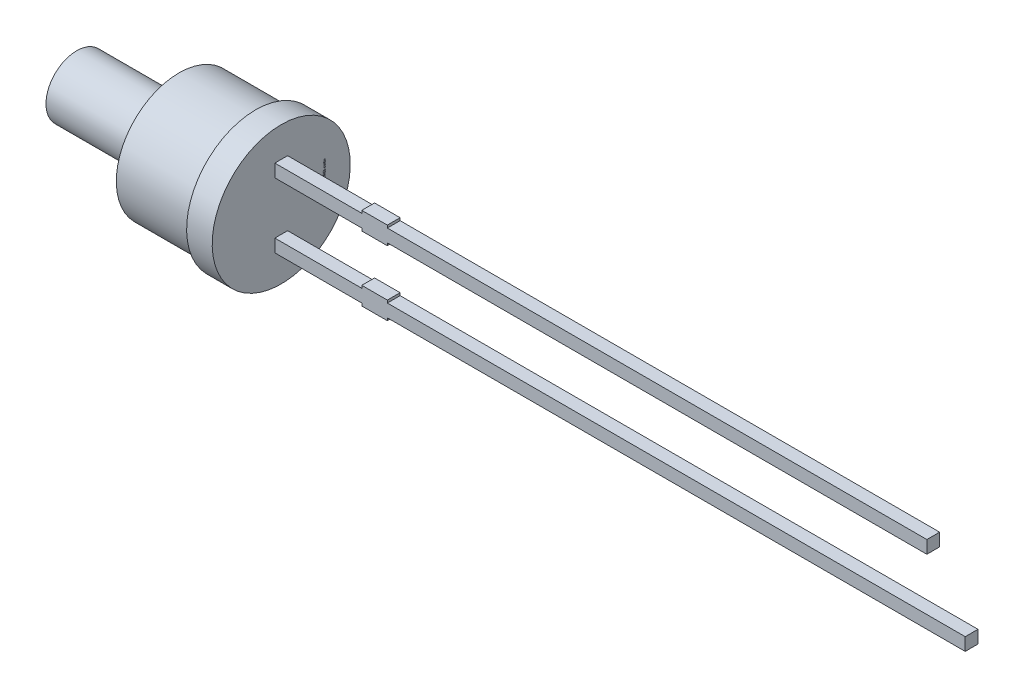
from build123d import *

# Parameters (mm, degrees)
SKETCH1_W          = 3.4
SKETCH1_H          = 0.5
SKETCH1_W_2        = 1
SKETCH1_W_3        = 21.1
SKETCH1_H_2        = 0.1
SKETCH1_W_4        = 22.6
EXTRUDE2_DEPTH     = 0.25
SKETCH2_W          = 0.026582279
SKETCH2_H          = 0.025316456
CUT_EXTRUDE1_DEPTH = 0.01


with BuildPart() as part:
    # Sketch1 → Extrude2 (new body, symmetric)
    with BuildSketch(Plane.XY):
        with Locations((1.7, 1.27)):
            Rectangle(SKETCH1_W, SKETCH1_H)
        with Locations((3.9, 1.27)):
            Rectangle(SKETCH1_W_2, SKETCH1_H)
        with Locations((14.95, 1.27)):
            Rectangle(SKETCH1_W_3, SKETCH1_H)
        with Locations((3.9, 1.57)):
            Rectangle(SKETCH1_W_2, SKETCH1_H_2)
        with Locations((3.9, 0.97)):
            Rectangle(SKETCH1_W_2, SKETCH1_H_2)
        with Locations((3.9, -1.27)):
            Rectangle(SKETCH1_W_2, SKETCH1_H)
        with Locations((3.9, -0.97)):
            Rectangle(SKETCH1_W_2, SKETCH1_H_2)
        with Locations((15.7, -1.27)):
            Rectangle(SKETCH1_W_4, SKETCH1_H)
        with Locations((1.7, -1.27)):
            Rectangle(SKETCH1_W, SKETCH1_H)
        with Locations((3.9, -1.57)):
            Rectangle(SKETCH1_W_2, SKETCH1_H_2)
    extrude(amount=EXTRUDE2_DEPTH, both=True)

    # Sketch1_6 → Revolve1 (revolve)
    with BuildSketch(Plane.XY):
        Polygon((-8, 0), (0, 0), (0, 1.02), (0, 1.52), (0, 2.7), (-1, 2.7), (-1, 2.45), (-4, 2.45), (-4, 1.2), (-8, 1.2), align=None)
    revolve(axis=Axis((0, 0, 0), (-1, 0, 0)))

    # Sketch2 → Cut-Extrude1 (cut)
    with BuildSketch(Plane(origin=(0, 0, 0), x_dir=(0, 0, -1), z_dir=(1, 0, 0))):
        Polygon((1.660977077, -0.572151899), (1.735660621, -0.595609177), (1.735660621, -0.620352057), (1.685324387, -0.636768196), (1.735660621, -0.652294304), (1.735660621, -0.678026108), (1.660977077, -0.701265823), (1.660977077, -0.676087816), (1.712460463, -0.663093354), (1.660977077, -0.646677215), (1.660977077, -0.625178006), (1.712460463, -0.608860759), (1.660977077, -0.596044304), align=None)
        Polygon((1.660977077, -0.437974684), (1.735660621, -0.461431962), (1.735660621, -0.486174842), (1.685324387, -0.502590981), (1.735660621, -0.518117089), (1.735660621, -0.543848892), (1.660977077, -0.567088608), (1.660977077, -0.541910601), (1.712460463, -0.528916139), (1.660977077, -0.5125), (1.660977077, -0.491000791), (1.712460463, -0.474683544), (1.660977077, -0.461867089), align=None)
        Polygon((1.660977077, -0.303797468), (1.735660621, -0.327254747), (1.735660621, -0.351997627), (1.685324387, -0.368413766), (1.735660621, -0.383939873), (1.735660621, -0.409671677), (1.660977077, -0.432911392), (1.660977077, -0.407733386), (1.712460463, -0.394738924), (1.660977077, -0.378322785), (1.660977077, -0.356823576), (1.712460463, -0.340506329), (1.660977077, -0.327689873), align=None)
        with Locations((1.722369482, -0.275949367)):
            Rectangle(SKETCH2_W, SKETCH2_H)
        with BuildLine():
            add(Edge.make_bspline(
                [(1.704489735, -0.159493671), (1.705711857, -0.15953019), (1.708111696, -0.159601901), (1.711619553, -0.160211194), (1.714943236, -0.161206237), (1.718104474, -0.162572352), (1.721068901, -0.164381718), (1.723864915, -0.166563022), (1.726479114, -0.169150529), (1.728887641, -0.17210691), (1.731092305, -0.175388005), (1.732983411, -0.178990487), (1.734609946, -0.182859482), (1.735941121, -0.187013878), (1.736932036, -0.191459348), (1.737655311, -0.196177156), (1.73812883, -0.201170496), (1.73817077, -0.204594085), (1.738192266, -0.206348892)],
                knots=[0, 0, 0, 0, 0.907462679, 1.781953809, 2.635804048, 3.480274448, 4.332887508, 5.208817748, 6.109340518, 7.059474472, 8.037577805, 9.041105121, 10.077237313, 11.152245627, 12.27748741, 13.457227022, 14.696666784, 16, 16, 16, 16], degree=3))
            add(Edge.make_bspline(
                [(1.738192266, -0.206348892), (1.738165001, -0.208366877), (1.738112198, -0.212275063), (1.737726825, -0.217942631), (1.737038875, -0.223206098), (1.736082295, -0.228103845), (1.73487901, -0.232708145), (1.733588366, -0.23714149), (1.732123785, -0.241422782), (1.731023649, -0.244195874), (1.730478659, -0.24556962)],
                knots=[0, 0, 0, 0, 1.203182053, 2.33017619, 3.384818652, 4.366208123, 5.30340534, 6.221361684, 7.118890722, 8, 8, 8, 8], degree=3))
            Line((1.730478659, -0.24556962), (1.706546697, -0.24556962))
            Line((1.706546697, -0.24556962), (1.706546697, -0.242721519))
            add(Edge.make_bspline(
                [(1.706546697, -0.242721519), (1.707627659, -0.241355956), (1.709783239, -0.238632846), (1.712551593, -0.234205888), (1.714924603, -0.229546876), (1.716907226, -0.224708482), (1.71848284, -0.219807114), (1.719609746, -0.214938046), (1.72034911, -0.210169064), (1.720430671, -0.207010742), (1.720470747, -0.205458861)],
                knots=[0, 0, 0, 0, 1.030738938, 2.055426519, 3.085610749, 4.123842265, 5.148648843, 6.130724483, 7.081507926, 8, 8, 8, 8], degree=3))
            add(Edge.make_bspline(
                [(1.720470747, -0.205458861), (1.720469411, -0.205030118), (1.72046655, -0.204112212), (1.720346437, -0.202649556), (1.720216037, -0.201000033), (1.72002204, -0.199225642), (1.719787668, -0.197432474), (1.719446485, -0.195764575), (1.719074378, -0.194257809), (1.71870728, -0.193351105), (1.718532456, -0.192919304)],
                knots=[0, 0, 0, 0, 0.806557331, 1.726776592, 2.760222249, 3.920734434, 5.085813889, 6.161303184, 7.124353598, 8, 8, 8, 8], degree=3))
            add(Edge.make_bspline(
                [(1.718532456, -0.192919304), (1.718303903, -0.192440047), (1.717854748, -0.191498205), (1.717048085, -0.190196887), (1.716141272, -0.189041565), (1.715179885, -0.18798482), (1.714029238, -0.187098496), (1.712622035, -0.186481634), (1.710974049, -0.186135268), (1.709798691, -0.186096466), (1.709177235, -0.186075949)],
                knots=[0, 0, 0, 0, 1.025060442, 2.01446193, 2.949256246, 3.85908539, 4.768290539, 5.73153362, 6.800575992, 8, 8, 8, 8], degree=3))
            add(Edge.make_bspline(
                [(1.709177235, -0.186075949), (1.708631627, -0.186107814), (1.707558802, -0.186170468), (1.706023253, -0.186747374), (1.704615841, -0.187657973), (1.70334243, -0.188931946), (1.702224158, -0.190544736), (1.701201514, -0.192462318), (1.700372601, -0.194733369), (1.699934007, -0.196370181), (1.699703342, -0.197231013)],
                knots=[0, 0, 0, 0, 0.825786558, 1.623739628, 2.456775365, 3.355767579, 4.339087636, 5.42728423, 6.646958453, 8, 8, 8, 8], degree=3))
            add(Edge.make_bspline(
                [(1.699703342, -0.197231013), (1.699257633, -0.199200151), (1.698342893, -0.203241458), (1.697163799, -0.209382993), (1.695929146, -0.21551983), (1.694717729, -0.219470134), (1.694125811, -0.221400316)],
                knots=[0, 0, 0, 0, 0.976116373, 2.003306214, 3.02438349, 4, 4, 4, 4], degree=3))
            add(Edge.make_bspline(
                [(1.694125811, -0.221400316), (1.69377209, -0.222438472), (1.693083541, -0.224459338), (1.691930857, -0.227358497), (1.690625846, -0.23000186), (1.689303386, -0.232459004), (1.687824785, -0.234653033), (1.68628404, -0.236646745), (1.684645082, -0.238419051), (1.682887697, -0.239944561), (1.681052629, -0.241289007), (1.679104414, -0.242440034), (1.677043097, -0.243408151), (1.674878641, -0.244200582), (1.67260938, -0.244819413), (1.670232111, -0.245239559), (1.66774886, -0.245538255), (1.666054491, -0.245559023), (1.665189893, -0.24556962)],
                knots=[0, 0, 0, 0, 1.287139616, 2.505537848, 3.65787682, 4.745319116, 5.777517297, 6.75878323, 7.700384896, 8.605120322, 9.485712598, 10.366814604, 11.256335458, 12.154696155, 13.068779358, 14.012730507, 14.985940713, 16, 16, 16, 16], degree=3))
            add(Edge.make_bspline(
                [(1.665189893, -0.24556962), (1.664033747, -0.24553232), (1.661758471, -0.245458913), (1.658429449, -0.244857463), (1.65528063, -0.243830953), (1.652277474, -0.242444593), (1.649463211, -0.2406171), (1.646785725, -0.238424977), (1.644293229, -0.235814667), (1.641994592, -0.23282934), (1.639915786, -0.229542493), (1.638079079, -0.226008488), (1.636572632, -0.222229636), (1.635291401, -0.218249751), (1.634339005, -0.214030359), (1.633619427, -0.209593388), (1.633206427, -0.204919526), (1.633155152, -0.201728115), (1.633128975, -0.200098892)],
                knots=[0, 0, 0, 0, 0.894901293, 1.761149761, 2.608783409, 3.453876344, 4.314933854, 5.200038827, 6.12799933, 7.103249695, 8.113098521, 9.136064399, 10.182719798, 11.259667356, 12.370545059, 13.528828137, 14.738461593, 16, 16, 16, 16], degree=3))
            add(Edge.make_bspline(
                [(1.633128975, -0.200098892), (1.63315133, -0.198430234), (1.633196001, -0.195095747), (1.633571542, -0.190113874), (1.634135141, -0.185162543), (1.634942124, -0.180292383), (1.635951587, -0.17560825), (1.637041034, -0.171185772), (1.638280959, -0.167106707), (1.639235062, -0.164532994), (1.639695431, -0.163291139)],
                knots=[0, 0, 0, 0, 1.065384654, 2.128962885, 3.18847586, 4.246683315, 5.279600907, 6.247539799, 7.154412252, 8, 8, 8, 8], degree=3))
            Line((1.639695431, -0.163291139), (1.662242899, -0.163291139))
            Line((1.662242899, -0.163291139), (1.662242899, -0.166119462))
            add(Edge.make_bspline(
                [(1.662242899, -0.166119462), (1.661443754, -0.16719302), (1.65981288, -0.16938391), (1.657708847, -0.173032632), (1.655777144, -0.177006091), (1.654047814, -0.181273774), (1.652628683, -0.185747065), (1.651599247, -0.190324411), (1.650960226, -0.194951528), (1.65088708, -0.198053112), (1.650850494, -0.19960443)],
                knots=[0, 0, 0, 0, 0.892231706, 1.82084296, 2.804411717, 3.838445872, 4.890103822, 5.931567007, 6.965432763, 8, 8, 8, 8], degree=3))
            add(Edge.make_bspline(
                [(1.650850494, -0.19960443), (1.650875143, -0.200699669), (1.650924569, -0.202895847), (1.651268048, -0.206171246), (1.651947752, -0.209404419), (1.652758858, -0.211441491), (1.653164577, -0.212460443)],
                knots=[0, 0, 0, 0, 0.99896713, 2.003134239, 3.001159596, 4, 4, 4, 4], degree=3))
            add(Edge.make_bspline(
                [(1.653164577, -0.212460443), (1.653365771, -0.212894149), (1.653768026, -0.21376127), (1.654547418, -0.214969172), (1.655464658, -0.216088766), (1.656517922, -0.217093311), (1.65769899, -0.217917451), (1.65896166, -0.218558729), (1.660324594, -0.218918158), (1.661258634, -0.218964182), (1.661728659, -0.218987342)],
                knots=[0, 0, 0, 0, 1.005120364, 2.009570296, 3.014977851, 4.045438181, 5.061509448, 6.035608779, 7.011484765, 8, 8, 8, 8], degree=3))
            add(Edge.make_bspline(
                [(1.661728659, -0.218987342), (1.66236659, -0.218952547), (1.663585618, -0.218886059), (1.665299314, -0.218286061), (1.666762426, -0.217288392), (1.667755419, -0.216135293), (1.668454179, -0.215018314), (1.668959418, -0.213977797), (1.669472841, -0.212778346), (1.669962039, -0.211400897), (1.670456085, -0.209865762), (1.670930755, -0.20815684), (1.671380314, -0.206274232), (1.671666466, -0.204958342), (1.671815684, -0.204272152)],
                knots=[0, 0, 0, 0, 1.174343879, 2.244064321, 3.303704314, 4.407076671, 5.02483983, 5.732197225, 6.53898402, 7.431906431, 8.428480183, 9.514816237, 10.704066255, 12, 12, 12, 12], degree=3))
            add(Edge.make_bspline(
                [(1.671815684, -0.204272152), (1.672191785, -0.202439393), (1.672929443, -0.198844747), (1.674032674, -0.193441658), (1.675335537, -0.187946356), (1.676467929, -0.184269987), (1.677056982, -0.182357595)],
                knots=[0, 0, 0, 0, 0.995794372, 1.953081347, 2.935223864, 4, 4, 4, 4], degree=3))
            add(Edge.make_bspline(
                [(1.677056982, -0.182357595), (1.677376338, -0.181411104), (1.67800105, -0.179559616), (1.67908577, -0.176918101), (1.680267734, -0.174468933), (1.681490659, -0.172191063), (1.682852352, -0.170127593), (1.684269683, -0.168242758), (1.685775657, -0.166545595), (1.68739101, -0.165056465), (1.689101687, -0.163728463), (1.690951339, -0.162613457), (1.692900502, -0.161626842), (1.694980936, -0.160835225), (1.697191898, -0.160250746), (1.699518782, -0.159818068), (1.701963934, -0.159526859), (1.703638403, -0.159504857), (1.704489735, -0.159493671)],
                knots=[0, 0, 0, 0, 1.237247399, 2.420255609, 3.534416354, 4.605351393, 5.620193117, 6.593738998, 7.524982051, 8.426564095, 9.311945829, 10.20281032, 11.097671666, 12.01534975, 12.954438892, 13.926750701, 14.945921247, 16, 16, 16, 16], degree=3))
        make_face()
        with BuildLine():
            Line((1.735660621, -0.067088608), (1.735660621, -0.091139241))
            Line((1.735660621, -0.091139241), (1.727828342, -0.091139241))
            add(Edge.make_bspline(
                [(1.727828342, -0.091139241), (1.728637246, -0.092232381), (1.7301968, -0.094339941), (1.732272412, -0.097515206), (1.734064738, -0.100536174), (1.735570762, -0.103474602), (1.736798417, -0.106474005), (1.737610572, -0.109708164), (1.738114653, -0.113209191), (1.73816582, -0.115636342), (1.738192266, -0.116890823)],
                knots=[0, 0, 0, 0, 1.15097647, 2.219065785, 3.209751872, 4.123278731, 5.012494873, 5.946522673, 6.938654008, 8, 8, 8, 8], degree=3))
            add(Edge.make_bspline(
                [(1.738192266, -0.116890823), (1.738169308, -0.117907091), (1.738124603, -0.11988606), (1.737783021, -0.122764448), (1.73723412, -0.125466099), (1.736467439, -0.127996041), (1.735456026, -0.130347067), (1.734205327, -0.132504746), (1.73274346, -0.134491413), (1.731067206, -0.136295066), (1.729146059, -0.137885611), (1.727023359, -0.139272682), (1.724688706, -0.140448488), (1.722137343, -0.141390128), (1.719378898, -0.142145061), (1.716399692, -0.142669038), (1.713212552, -0.142989618), (1.711017423, -0.143021559), (1.70988926, -0.143037975)],
                knots=[0, 0, 0, 0, 1.108887696, 2.159324556, 3.158383213, 4.114277414, 5.039206009, 5.945047284, 6.830075132, 7.726032535, 8.625162295, 9.545152215, 10.487958828, 11.471559655, 12.508379831, 13.604991163, 14.769110247, 16, 16, 16, 16], degree=3))
            Line((1.70988926, -0.143037975), (1.660977077, -0.143037975))
            Line((1.660977077, -0.143037975), (1.660977077, -0.118987342))
            Line((1.660977077, -0.118987342), (1.69855619, -0.118987342))
            add(Edge.make_bspline(
                [(1.69855619, -0.118987342), (1.699472661, -0.118985706), (1.701226877, -0.118982576), (1.703732684, -0.118900237), (1.706000856, -0.118779336), (1.708042885, -0.118640631), (1.709889636, -0.118387615), (1.711555797, -0.118009906), (1.713075398, -0.11753908), (1.7139821, -0.117074761), (1.714418532, -0.116851266)],
                knots=[0, 0, 0, 0, 1.361401701, 2.605856924, 3.723918663, 4.735739235, 5.645738665, 6.489217889, 7.27279937, 8, 8, 8, 8], degree=3))
            add(Edge.make_bspline(
                [(1.714418532, -0.116851266), (1.714817171, -0.116621224), (1.71560086, -0.116168982), (1.716608141, -0.115249197), (1.717444533, -0.114173114), (1.718119231, -0.112903872), (1.718594392, -0.111407752), (1.718981572, -0.109682844), (1.71915179, -0.107690452), (1.719186531, -0.106283083), (1.719204925, -0.105537975)],
                knots=[0, 0, 0, 0, 0.848923305, 1.668910138, 2.502822694, 3.358979167, 4.311113223, 5.396624103, 6.621686681, 8, 8, 8, 8], degree=3))
            add(Edge.make_bspline(
                [(1.719204925, -0.105537975), (1.719184976, -0.104997054), (1.71914399, -0.103885683), (1.718954959, -0.102174294), (1.718550799, -0.100392654), (1.71790683, -0.097874301), (1.716719866, -0.094699608), (1.71536234, -0.092335231), (1.714675652, -0.091139241)],
                knots=[0, 0, 0, 0, 0.638098464, 1.31103257, 2.025970928, 2.789492669, 4.376004971, 6, 6, 6, 6], degree=3))
            Line((1.714675652, -0.091139241), (1.660977077, -0.091139241))
            Line((1.660977077, -0.091139241), (1.660977077, -0.067088608))
            Line((1.660977077, -0.067088608), (1.735660621, -0.067088608))
        make_face()
        with BuildLine():
            Line((1.735660621, 0.030379747), (1.735660621, 0.006329114))
            Line((1.735660621, 0.006329114), (1.698081507, 0.006329114))
            add(Edge.make_bspline(
                [(1.698081507, 0.006329114), (1.696551084, 0.006308303), (1.693492201, 0.006266709), (1.689734799, 0.005938503), (1.686887723, 0.005599031), (1.685057972, 0.005224273), (1.683509655, 0.004793931), (1.682623915, 0.004381503), (1.682219165, 0.004193038)],
                knots=[0, 0, 0, 0, 1.709225407, 3.416259723, 4.21101956, 4.910102269, 5.501957085, 6, 6, 6, 6], degree=3))
            add(Edge.make_bspline(
                [(1.682219165, 0.004193038), (1.681821033, 0.003948611), (1.681040439, 0.003469379), (1.680028554, 0.002531536), (1.67919181, 0.001434991), (1.678528962, 0.000155857), (1.678034554, -0.001325729), (1.677688272, -0.003045559), (1.677476049, -0.005025093), (1.677447748, -0.00643402), (1.677432773, -0.007179589)],
                knots=[0, 0, 0, 0, 0.860284341, 1.686708632, 2.528476982, 3.393563585, 4.332150703, 5.400907339, 6.624626855, 8, 8, 8, 8], degree=3))
            add(Edge.make_bspline(
                [(1.677432773, -0.007179589), (1.677492718, -0.008310545), (1.677615041, -0.010618379), (1.678283774, -0.013492792), (1.679137004, -0.015806428), (1.679902918, -0.017657215), (1.680860218, -0.019572829), (1.681586909, -0.020856385), (1.681962045, -0.021518987)],
                knots=[0, 0, 0, 0, 1.338233385, 2.730803257, 3.468495571, 4.255080394, 5.099229486, 6, 6, 6, 6], degree=3))
            Line((1.681962045, -0.021518987), (1.735660621, -0.021518987))
            Line((1.735660621, -0.021518987), (1.735660621, -0.04556962))
            Line((1.735660621, -0.04556962), (1.660977077, -0.04556962))
            Line((1.660977077, -0.04556962), (1.660977077, -0.021518987))
            Line((1.660977077, -0.021518987), (1.668809355, -0.021518987))
            add(Edge.make_bspline(
                [(1.668809355, -0.021518987), (1.668002917, -0.02046175), (1.666433138, -0.018403774), (1.664399729, -0.015227022), (1.662589872, -0.01215631), (1.661077738, -0.009101788), (1.659879138, -0.005977291), (1.659063535, -0.00270966), (1.658520586, 0.000707053), (1.658470775, 0.003043726), (1.658445431, 0.004232595)],
                knots=[0, 0, 0, 0, 1.126064518, 2.191951536, 3.19307265, 4.144813015, 5.076393104, 6.021983703, 6.993610568, 8, 8, 8, 8], degree=3))
            add(Edge.make_bspline(
                [(1.658445431, 0.004232595), (1.658470831, 0.00522886), (1.658520417, 0.007173746), (1.658829969, 0.010008596), (1.659381192, 0.012679702), (1.660177049, 0.015173087), (1.661168409, 0.01750877), (1.662372384, 0.019682454), (1.663835681, 0.021668259), (1.665495559, 0.023496579), (1.667387087, 0.025135042), (1.669515578, 0.026534404), (1.671858065, 0.027730277), (1.67440761, 0.028717595), (1.677186568, 0.029468634), (1.680179948, 0.029984818), (1.683390846, 0.030339095), (1.685606852, 0.030365925), (1.686748437, 0.030379747)],
                knots=[0, 0, 0, 0, 1.088244909, 2.124447647, 3.110254678, 4.062235362, 4.978491991, 5.877983887, 6.769571508, 7.666696544, 8.570415953, 9.495151274, 10.442024977, 11.43832337, 12.476026402, 13.580659577, 14.753665747, 16, 16, 16, 16], degree=3))
            Line((1.686748437, 0.030379747), (1.735660621, 0.030379747))
        make_face()
        Polygon((1.735660621, 0.125316456), (1.735660621, 0.053164557), (1.635660621, 0.053164557), (1.635660621, 0.078481013), (1.716673279, 0.078481013), (1.716673279, 0.125316456), align=None)
        Polygon((1.735660621, 0.212658228), (1.735660621, 0.140506329), (1.635660621, 0.140506329), (1.635660621, 0.212658228), (1.654647963, 0.212658228), (1.654647963, 0.165822785), (1.672369482, 0.165822785), (1.672369482, 0.208860759), (1.691356823, 0.208860759), (1.691356823, 0.165822785), (1.716673279, 0.165822785), (1.716673279, 0.212658228), align=None)
        with BuildLine():
            add(Edge.make_bspline(
                [(1.685759513, 0.329113924), (1.686907202, 0.329094609), (1.689180088, 0.329056357), (1.692544895, 0.328761165), (1.69581057, 0.32823514), (1.698994819, 0.327555959), (1.702073746, 0.326633453), (1.705081324, 0.325551739), (1.707986817, 0.324242093), (1.710788252, 0.322737241), (1.713460354, 0.321087768), (1.715980563, 0.319313019), (1.718363781, 0.31746724), (1.720558675, 0.315477927), (1.722600694, 0.313398746), (1.724491509, 0.311223217), (1.726194939, 0.308918153), (1.727217824, 0.30731099), (1.72772945, 0.30650712)],
                knots=[0, 0, 0, 0, 1.105570398, 2.18947457, 3.250358341, 4.290584537, 5.323553275, 6.344225964, 7.367641686, 8.3905646, 9.405808457, 10.390761353, 11.358902336, 12.307789878, 13.241960776, 14.165076779, 15.082208636, 16, 16, 16, 16], degree=3))
            add(Edge.make_bspline(
                [(1.72772945, 0.30650712), (1.728441801, 0.30526794), (1.729870137, 0.302783257), (1.731535528, 0.298798692), (1.732953564, 0.294671424), (1.733960775, 0.290304109), (1.734732254, 0.285666021), (1.735282737, 0.280667978), (1.735586833, 0.275267531), (1.735635464, 0.27153255), (1.735660621, 0.269600475)],
                knots=[0, 0, 0, 0, 0.896331627, 1.797236794, 2.705411718, 3.632841792, 4.606367508, 5.655603524, 6.787262262, 8, 8, 8, 8], degree=3))
            Line((1.735660621, 0.269600475), (1.735660621, 0.234177215))
            Line((1.735660621, 0.234177215), (1.635660621, 0.234177215))
            Line((1.635660621, 0.234177215), (1.635660621, 0.270609177))
            add(Edge.make_bspline(
                [(1.635660621, 0.270609177), (1.635677515, 0.272587865), (1.635710102, 0.276404509), (1.636123412, 0.281915405), (1.636731832, 0.287010921), (1.637627841, 0.291699732), (1.638735728, 0.296010589), (1.640128196, 0.299933416), (1.641620381, 0.303549763), (1.642894989, 0.305728284), (1.643512678, 0.306784019)],
                knots=[0, 0, 0, 0, 1.267100211, 2.444079055, 3.537724964, 4.552266402, 5.499704501, 6.385138932, 7.217420793, 8, 8, 8, 8], degree=3))
            add(Edge.make_bspline(
                [(1.643512678, 0.306784019), (1.644049218, 0.307634972), (1.645116132, 0.309327097), (1.646897984, 0.311728312), (1.648854061, 0.313957739), (1.65090588, 0.316086242), (1.653108767, 0.318066056), (1.655447471, 0.319909269), (1.657925578, 0.321613036), (1.660534998, 0.323171192), (1.663265238, 0.324591277), (1.666137583, 0.325783356), (1.669120456, 0.326822718), (1.672219396, 0.327668801), (1.675436785, 0.32832513), (1.678774265, 0.328771214), (1.682227454, 0.329054647), (1.684572247, 0.329093999), (1.685759513, 0.329113924)],
                knots=[0, 0, 0, 0, 0.964043478, 1.917004671, 2.862223898, 3.805158963, 4.749279098, 5.698713747, 6.657523689, 7.629652222, 8.610369353, 9.604453025, 10.607693792, 11.636365947, 12.681120053, 13.752669011, 14.862083412, 16, 16, 16, 16], degree=3))
        make_face()
        with BuildLine():
            add(Edge.make_bspline(
                [(1.685601285, 0.302531646), (1.68402343, 0.302485243), (1.680977761, 0.302395675), (1.67657356, 0.301732132), (1.672540295, 0.300552601), (1.669423791, 0.299223365), (1.667150776, 0.297884821), (1.665552445, 0.296757527), (1.664038261, 0.295507799), (1.662629417, 0.294117207), (1.661322382, 0.292582018), (1.660093471, 0.29092076), (1.658964825, 0.289120719), (1.65830482, 0.287847687), (1.657970747, 0.287203323)],
                knots=[0, 0, 0, 0, 1.694561208, 3.270940604, 4.767926833, 6.198032689, 6.896357436, 7.597727349, 8.296769799, 9.00280713, 9.720956486, 10.460265288, 11.220639329, 12, 12, 12, 12], degree=3))
            add(Edge.make_bspline(
                [(1.657970747, 0.287203323), (1.657664233, 0.286528388), (1.6570567, 0.285190619), (1.656322614, 0.283120344), (1.655760286, 0.281027643), (1.655287864, 0.278833415), (1.655010728, 0.276356655), (1.654798051, 0.273434164), (1.654661124, 0.269977491), (1.654652553, 0.267490895), (1.654647963, 0.266159019)],
                knots=[0, 0, 0, 0, 0.826913061, 1.638999358, 2.447478739, 3.243919028, 4.140906711, 5.225381046, 6.513851968, 8, 8, 8, 8], degree=3))
            Line((1.654647963, 0.266159019), (1.654647963, 0.259493671))
            Line((1.654647963, 0.259493671), (1.716673279, 0.259493671))
            Line((1.716673279, 0.259493671), (1.716673279, 0.266159019))
            add(Edge.make_bspline(
                [(1.716673279, 0.266159019), (1.716668237, 0.266917211), (1.716658503, 0.268380947), (1.716619351, 0.270497394), (1.716559202, 0.272462176), (1.716486803, 0.274269462), (1.716374153, 0.275919264), (1.716200163, 0.277406458), (1.716063466, 0.278743267), (1.715786342, 0.280315786), (1.715380094, 0.282170955), (1.714697024, 0.28433775), (1.713847426, 0.286478448), (1.71316235, 0.287866999), (1.712816475, 0.288568038)],
                knots=[0, 0, 0, 0, 1.186788252, 2.291168447, 3.31326867, 4.263560303, 5.122314491, 5.900668105, 6.60723418, 7.224768558, 8.398927205, 9.577205322, 10.776800932, 12, 12, 12, 12], degree=3))
            add(Edge.make_bspline(
                [(1.712816475, 0.288568038), (1.712472997, 0.28915175), (1.71179751, 0.290299682), (1.710691671, 0.291943861), (1.709456586, 0.293430472), (1.708173795, 0.294836999), (1.706782216, 0.29608816), (1.705338676, 0.297265459), (1.703764134, 0.2982507), (1.701575199, 0.29949957), (1.698548042, 0.300743145), (1.694576118, 0.301776761), (1.690216963, 0.302415553), (1.687179258, 0.302491957), (1.685601285, 0.302531646)],
                knots=[0, 0, 0, 0, 0.755184287, 1.485151634, 2.206180267, 2.908413556, 3.605665444, 4.291074465, 4.982332562, 5.673512475, 7.100235687, 8.614142391, 10.24117603, 12, 12, 12, 12], degree=3))
        make_face(mode=Mode.SUBTRACT)
        with Locations((1.722369482, 0.360759494)):
            Rectangle(SKETCH2_W, SKETCH2_H)
        with BuildLine():
            add(Edge.make_bspline(
                [(1.738192266, 0.435403481), (1.738170448, 0.433813372), (1.738127622, 0.430692242), (1.737650809, 0.426120851), (1.736932739, 0.421755856), (1.735913161, 0.417608916), (1.734563788, 0.413705632), (1.732928716, 0.410033248), (1.730928878, 0.406634041), (1.729346261, 0.404567057), (1.728560146, 0.403540348)],
                knots=[0, 0, 0, 0, 1.123640227, 2.2055255, 3.245221982, 4.248949655, 5.220213072, 6.160941522, 7.086505793, 8, 8, 8, 8], degree=3))
            add(Edge.make_bspline(
                [(1.728560146, 0.403540348), (1.727705313, 0.402588713), (1.725998953, 0.400689124), (1.723028409, 0.398221497), (1.719739436, 0.396103421), (1.716147783, 0.394291165), (1.712227898, 0.392859214), (1.707978004, 0.391866679), (1.703420674, 0.391239075), (1.70027247, 0.391173123), (1.698655083, 0.391139241)],
                knots=[0, 0, 0, 0, 0.916342154, 1.829140869, 2.758848968, 3.716597128, 4.708179637, 5.743612459, 6.840783343, 8, 8, 8, 8], degree=3))
            add(Edge.make_bspline(
                [(1.698655083, 0.391139241), (1.696951856, 0.391178001), (1.693650776, 0.391253124), (1.688878588, 0.391916883), (1.684460907, 0.392986496), (1.680408999, 0.394524054), (1.676715808, 0.396454496), (1.673343973, 0.398718989), (1.670301049, 0.401339514), (1.668555609, 0.403346653), (1.667681982, 0.404351266)],
                knots=[0, 0, 0, 0, 1.171797512, 2.271099083, 3.308930235, 4.294129479, 5.24602549, 6.17106565, 7.084581485, 8, 8, 8, 8], degree=3))
            add(Edge.make_bspline(
                [(1.667681982, 0.404351266), (1.666913328, 0.405377093), (1.665366736, 0.407441138), (1.663470016, 0.410840018), (1.661872049, 0.414456691), (1.66059709, 0.418279973), (1.659647844, 0.422262676), (1.658952079, 0.426332115), (1.658523936, 0.430476032), (1.658471725, 0.433266397), (1.658445431, 0.434671677)],
                knots=[0, 0, 0, 0, 0.952013349, 1.915525331, 2.885385798, 3.888123097, 4.906830296, 5.926067872, 6.955529031, 8, 8, 8, 8], degree=3))
            add(Edge.make_bspline(
                [(1.658445431, 0.434671677), (1.658461789, 0.43591849), (1.658493956, 0.438370146), (1.658825113, 0.441968871), (1.659324131, 0.445420869), (1.660067701, 0.448720159), (1.660990516, 0.451886357), (1.662014664, 0.454949807), (1.663154574, 0.457914044), (1.664038531, 0.459814797), (1.664477868, 0.460759494)],
                knots=[0, 0, 0, 0, 1.107572103, 2.177862056, 3.208491727, 4.204802822, 5.180069889, 6.137814326, 7.074472616, 8, 8, 8, 8], degree=3))
            Line((1.664477868, 0.460759494), (1.685027709, 0.460759494))
            Line((1.685027709, 0.460759494), (1.685027709, 0.45741693))
            add(Edge.make_bspline(
                [(1.685027709, 0.45741693), (1.684610818, 0.456917135), (1.683703881, 0.455829843), (1.682276996, 0.454048018), (1.680755731, 0.451893107), (1.679867063, 0.450248438), (1.679390842, 0.449367089)],
                knots=[0, 0, 0, 0, 0.792806788, 1.724728901, 2.780722718, 4, 4, 4, 4], degree=3))
            add(Edge.make_bspline(
                [(1.679390842, 0.449367089), (1.678951297, 0.448438429), (1.678046806, 0.446527444), (1.677182521, 0.443980324), (1.676646539, 0.441780001), (1.676384515, 0.439972051), (1.6761969, 0.43803794), (1.676177117, 0.436702768), (1.67616695, 0.436016614)],
                knots=[0, 0, 0, 0, 1.332411269, 2.741822805, 3.48048496, 4.268099981, 5.109965479, 6, 6, 6, 6], degree=3))
            add(Edge.make_bspline(
                [(1.67616695, 0.436016614), (1.676186291, 0.435250982), (1.676223772, 0.433767223), (1.676503685, 0.431606761), (1.676972258, 0.42958248), (1.6776485, 0.427693249), (1.678508806, 0.425938689), (1.679528966, 0.42430302), (1.680780955, 0.422827378), (1.682199387, 0.421485751), (1.683789712, 0.420298179), (1.685516251, 0.419271451), (1.68737413, 0.418388718), (1.689372041, 0.417686826), (1.691501903, 0.417129316), (1.693764713, 0.416739751), (1.696164311, 0.416497972), (1.697810606, 0.416470029), (1.698655083, 0.416455696)],
                knots=[0, 0, 0, 0, 1.087164589, 2.106874378, 3.088024391, 4.032801718, 4.949890679, 5.859058447, 6.763003849, 7.690312844, 8.626654282, 9.575690722, 10.539030902, 11.54301425, 12.578634972, 13.662366762, 14.800897888, 16, 16, 16, 16], degree=3))
            add(Edge.make_bspline(
                [(1.698655083, 0.416455696), (1.699519239, 0.416470471), (1.701198252, 0.416499177), (1.703639863, 0.416732691), (1.705921294, 0.417148582), (1.708046614, 0.41771983), (1.710012632, 0.418444178), (1.711810029, 0.419349295), (1.713466836, 0.420385652), (1.714929448, 0.42163021), (1.716245769, 0.422994093), (1.717381904, 0.424508985), (1.718330049, 0.426168224), (1.719134512, 0.427950405), (1.71971291, 0.429883445), (1.720149602, 0.431939982), (1.720438159, 0.434129537), (1.720459722, 0.435639891), (1.720470747, 0.436412184)],
                knots=[0, 0, 0, 0, 1.230336593, 2.390482092, 3.487897344, 4.52859895, 5.520747884, 6.465347575, 7.38981449, 8.296085817, 9.192433006, 10.084246191, 10.984321635, 11.908883871, 12.862027947, 13.850751296, 14.901019963, 16, 16, 16, 16], degree=3))
            add(Edge.make_bspline(
                [(1.720470747, 0.436412184), (1.720461893, 0.437137934), (1.72044463, 0.438552757), (1.720237187, 0.440613478), (1.719926799, 0.442563904), (1.719485167, 0.444396174), (1.718979968, 0.446107761), (1.718402771, 0.447669394), (1.717800126, 0.449082516), (1.717332312, 0.449943788), (1.717108406, 0.450356013)],
                knots=[0, 0, 0, 0, 1.201100869, 2.341500598, 3.425337164, 4.468451875, 5.459559168, 6.378110228, 7.223726512, 8, 8, 8, 8], degree=3))
            add(Edge.make_bspline(
                [(1.717108406, 0.450356013), (1.71668072, 0.451064369), (1.71585876, 0.452425742), (1.714438301, 0.454250861), (1.713031861, 0.455894986), (1.712075093, 0.456919091), (1.711609988, 0.45741693)],
                knots=[0, 0, 0, 0, 1.105932972, 2.12546697, 3.088749538, 4, 4, 4, 4], degree=3))
            Line((1.711609988, 0.45741693), (1.711609988, 0.460759494))
            Line((1.711609988, 0.460759494), (1.732318058, 0.460759494))
            add(Edge.make_bspline(
                [(1.732318058, 0.460759494), (1.7327556, 0.459814117), (1.733630789, 0.457923136), (1.73478394, 0.455008359), (1.735756819, 0.452015116), (1.736649166, 0.448963886), (1.737347361, 0.445794254), (1.737836591, 0.442476905), (1.73813833, 0.438995601), (1.738174042, 0.436617185), (1.738192266, 0.435403481)],
                knots=[0, 0, 0, 0, 0.952024047, 1.90427691, 2.862762905, 3.827874523, 4.80891974, 5.826446878, 6.890837857, 8, 8, 8, 8], degree=3))
        make_face()
        with BuildLine():
            add(Edge.make_bspline(
                [(1.698358406, 0.553164557), (1.699863237, 0.553139637), (1.702796559, 0.553091062), (1.707069378, 0.552554854), (1.71109982, 0.551731391), (1.714900658, 0.550598066), (1.718443704, 0.549080213), (1.721739657, 0.547237799), (1.72479184, 0.545064208), (1.727582067, 0.542573889), (1.730080258, 0.539772404), (1.732276452, 0.536698638), (1.7340835, 0.533328772), (1.735610049, 0.529720026), (1.73676615, 0.525830719), (1.737584101, 0.521671624), (1.738118432, 0.517254115), (1.738167244, 0.514215749), (1.738192266, 0.512658228)],
                knots=[0, 0, 0, 0, 1.120122129, 2.18341868, 3.201215738, 4.181270334, 5.131540819, 6.065757527, 6.988093576, 7.916512302, 8.844931028, 9.778115023, 10.722851943, 11.686686084, 12.691660064, 13.738321946, 14.84062285, 16, 16, 16, 16], degree=3))
            add(Edge.make_bspline(
                [(1.738192266, 0.512658228), (1.738167327, 0.51110068), (1.738118675, 0.508062261), (1.737583204, 0.503645127), (1.736770487, 0.499490907), (1.735601252, 0.495606256), (1.734089162, 0.491991945), (1.73227572, 0.488618118), (1.730080467, 0.485543936), (1.727581956, 0.482742733), (1.724792072, 0.480251696), (1.721738842, 0.478080692), (1.718449049, 0.476229753), (1.714891775, 0.47474936), (1.711104566, 0.473576829), (1.707068569, 0.472764049), (1.702796778, 0.472224732), (1.699863312, 0.472176594), (1.698358406, 0.472151899)],
                knots=[0, 0, 0, 0, 1.159424321, 2.261770074, 3.308474541, 4.308788811, 5.277191138, 6.221966496, 7.15518846, 8.08364496, 9.01210146, 9.934475036, 10.868729753, 11.817121636, 12.798654016, 13.816492484, 14.879832297, 16, 16, 16, 16], degree=3))
            add(Edge.make_bspline(
                [(1.698358406, 0.472151899), (1.696846973, 0.472177), (1.693893945, 0.472226044), (1.689595198, 0.472761711), (1.685534101, 0.473578673), (1.681721551, 0.474744205), (1.678159075, 0.476250482), (1.674852886, 0.478097428), (1.671806112, 0.480293183), (1.669015948, 0.482802618), (1.66652142, 0.485615383), (1.664343315, 0.488702882), (1.662534522, 0.492066422), (1.661006757, 0.495666774), (1.659874211, 0.499554435), (1.659056055, 0.503691062), (1.658518145, 0.508088545), (1.65847011, 0.511107271), (1.658445431, 0.512658228)],
                knots=[0, 0, 0, 0, 1.123883205, 2.195836198, 3.217400301, 4.202580581, 5.156396106, 6.089661422, 7.013912723, 7.944661364, 8.875797629, 9.805201257, 10.748976071, 11.711828658, 12.709674189, 13.755270167, 14.846705509, 16, 16, 16, 16], degree=3))
            add(Edge.make_bspline(
                [(1.658445431, 0.512658228), (1.658470143, 0.514228972), (1.658518256, 0.517287148), (1.659054595, 0.521730477), (1.659867122, 0.525904607), (1.661035191, 0.529802216), (1.662538461, 0.533426224), (1.664393408, 0.5367734), (1.666567758, 0.539858359), (1.669097586, 0.542626621), (1.67189254, 0.54511038), (1.67495022, 0.547272736), (1.678257796, 0.549108213), (1.681819671, 0.550583955), (1.685612303, 0.551758158), (1.68964673, 0.552578569), (1.693921637, 0.553084721), (1.69685378, 0.553137483), (1.698358406, 0.553164557)],
                knots=[0, 0, 0, 0, 1.167473013, 2.273023816, 3.322954552, 4.326451713, 5.293391623, 6.234801871, 7.166614545, 8.093305908, 9.017100806, 9.942078766, 10.872536262, 11.824015763, 12.804065898, 13.820367293, 14.881523901, 16, 16, 16, 16], degree=3))
        make_face()
        with BuildLine():
            add(Edge.make_bspline(
                [(1.716851285, 0.523457278), (1.716351021, 0.523811854), (1.715332925, 0.524533458), (1.713633428, 0.525414912), (1.71179164, 0.526165223), (1.709766882, 0.526786059), (1.707476537, 0.527300861), (1.704825584, 0.52759945), (1.701790834, 0.527833002), (1.699638005, 0.52784287), (1.698496855, 0.527848101)],
                knots=[0, 0, 0, 0, 0.765135464, 1.557141201, 2.384449913, 3.246599353, 4.1996426, 5.311961702, 6.575150963, 8, 8, 8, 8], degree=3))
            add(Edge.make_bspline(
                [(1.698496855, 0.527848101), (1.697421981, 0.527830368), (1.69536264, 0.527796392), (1.692402775, 0.527610608), (1.689713277, 0.527259147), (1.687288569, 0.526765631), (1.685116499, 0.526158041), (1.683184171, 0.525423239), (1.681470216, 0.524589801), (1.680465095, 0.523904047), (1.679984197, 0.523575949)],
                knots=[0, 0, 0, 0, 1.337015307, 2.56157572, 3.686511827, 4.707709802, 5.636963675, 6.488272502, 7.276717686, 8, 8, 8, 8], degree=3))
            add(Edge.make_bspline(
                [(1.679984197, 0.523575949), (1.679546552, 0.523237287), (1.67869181, 0.522575862), (1.677585489, 0.521419361), (1.676715682, 0.52013186), (1.676010949, 0.518766917), (1.675534853, 0.517311235), (1.675169266, 0.515811038), (1.674950843, 0.51425344), (1.674917791, 0.513192902), (1.674901127, 0.512658228)],
                knots=[0, 0, 0, 0, 1.058303018, 2.066917725, 3.046948061, 4.023234392, 4.996907708, 5.970172105, 6.976653347, 8, 8, 8, 8], degree=3))
            add(Edge.make_bspline(
                [(1.674901127, 0.512658228), (1.674912157, 0.512130325), (1.674933731, 0.511097766), (1.675112248, 0.509594689), (1.675412247, 0.508179036), (1.675816432, 0.50683387), (1.676427808, 0.505548722), (1.677276626, 0.504317445), (1.678353206, 0.503102058), (1.679203541, 0.50236373), (1.679647963, 0.501977848)],
                knots=[0, 0, 0, 0, 1.04189444, 2.037910168, 2.982338511, 3.896140384, 4.804271323, 5.778885192, 6.839150358, 8, 8, 8, 8], degree=3))
            add(Edge.make_bspline(
                [(1.679647963, 0.501977848), (1.68012163, 0.501642414), (1.681115738, 0.500938424), (1.682836108, 0.500089235), (1.684781599, 0.499319936), (1.686972734, 0.498640648), (1.689440274, 0.498109463), (1.692198888, 0.497751274), (1.695248822, 0.497506594), (1.697382129, 0.497481478), (1.698496855, 0.497468354)],
                knots=[0, 0, 0, 0, 0.70629823, 1.482341141, 2.329662943, 3.254583898, 4.274063958, 5.401087491, 6.641978366, 8, 8, 8, 8], degree=3))
            add(Edge.make_bspline(
                [(1.698496855, 0.497468354), (1.69949959, 0.497474304), (1.701441714, 0.497485828), (1.704244098, 0.497727894), (1.706852365, 0.498015163), (1.709241016, 0.498500249), (1.71143018, 0.499078592), (1.71338832, 0.499811255), (1.715136054, 0.500650609), (1.716159734, 0.501345833), (1.716653501, 0.501681171)],
                knots=[0, 0, 0, 0, 1.270931856, 2.461574991, 3.564842381, 4.596079713, 5.549239655, 6.432768418, 7.244053423, 8, 8, 8, 8], degree=3))
            add(Edge.make_bspline(
                [(1.716653501, 0.501681171), (1.717070405, 0.502021462), (1.717892359, 0.502692369), (1.718966642, 0.503841178), (1.719846261, 0.50510292), (1.720542966, 0.506463378), (1.721075883, 0.507926821), (1.721476301, 0.509481783), (1.721687364, 0.511142692), (1.721719893, 0.512275314), (1.72173657, 0.512856013)],
                knots=[0, 0, 0, 0, 1.011235752, 1.993715204, 2.946409587, 3.894575777, 4.859533504, 5.869856863, 6.907869553, 8, 8, 8, 8], degree=3))
            add(Edge.make_bspline(
                [(1.72173657, 0.512856013), (1.721686017, 0.513864117), (1.721585692, 0.515864737), (1.720844026, 0.518276041), (1.719986284, 0.520072218), (1.71915162, 0.521339493), (1.718087024, 0.522470719), (1.717268503, 0.52312419), (1.716851285, 0.523457278)],
                knots=[0, 0, 0, 0, 1.494110474, 2.96511767, 3.704956058, 4.446088323, 5.207938169, 6, 6, 6, 6], degree=3))
        make_face(mode=Mode.SUBTRACT)
        with BuildLine():
            Line((1.681962045, 0.644303797), (1.735660621, 0.644303797))
            Line((1.735660621, 0.644303797), (1.735660621, 0.620253165))
            Line((1.735660621, 0.620253165), (1.697804608, 0.620253165))
            add(Edge.make_bspline(
                [(1.697804608, 0.620253165), (1.696914608, 0.620246898), (1.695207044, 0.620234875), (1.692746714, 0.620212363), (1.690499371, 0.620096991), (1.688452036, 0.620000439), (1.68659565, 0.619801755), (1.684915942, 0.619524083), (1.683412946, 0.619095228), (1.682511831, 0.618687802), (1.682080716, 0.61849288)],
                knots=[0, 0, 0, 0, 1.33997484, 2.570892857, 3.703483919, 4.727540125, 5.655929516, 6.512630168, 7.288405602, 8, 8, 8, 8], degree=3))
            add(Edge.make_bspline(
                [(1.682080716, 0.61849288), (1.681695506, 0.618282873), (1.680931924, 0.617866586), (1.679961773, 0.616999731), (1.679157739, 0.615984414), (1.678482167, 0.614820738), (1.678022121, 0.613425719), (1.677660976, 0.611817719), (1.677484492, 0.609952288), (1.677450661, 0.608630238), (1.677432773, 0.607931171)],
                knots=[0, 0, 0, 0, 0.859137151, 1.703023591, 2.531884144, 3.395689496, 4.329139829, 5.403231912, 6.626892925, 8, 8, 8, 8], degree=3))
            add(Edge.make_bspline(
                [(1.677432773, 0.607931171), (1.677455639, 0.607343691), (1.677501578, 0.606163433), (1.677754308, 0.604403162), (1.678218093, 0.602668945), (1.679063373, 0.600450118), (1.680308483, 0.597858933), (1.681424313, 0.595887005), (1.681962045, 0.594936709)],
                knots=[0, 0, 0, 0, 0.759205818, 1.525260036, 2.291692926, 3.073215079, 4.589547174, 6, 6, 6, 6], degree=3))
            Line((1.681962045, 0.594936709), (1.735660621, 0.594936709))
            Line((1.735660621, 0.594936709), (1.735660621, 0.570886076))
            Line((1.735660621, 0.570886076), (1.660977077, 0.570886076))
            Line((1.660977077, 0.570886076), (1.660977077, 0.594936709))
            Line((1.660977077, 0.594936709), (1.668809355, 0.594936709))
            add(Edge.make_bspline(
                [(1.668809355, 0.594936709), (1.668027494, 0.595957498), (1.666509436, 0.597939458), (1.664466781, 0.60095963), (1.662686716, 0.603901326), (1.661136273, 0.606795115), (1.659925559, 0.609757591), (1.659075899, 0.612850643), (1.658546837, 0.616094734), (1.658479644, 0.618312831), (1.658445431, 0.619442247)],
                knots=[0, 0, 0, 0, 1.135996309, 2.205644619, 3.219721285, 4.173434518, 5.103784725, 6.040859173, 7.002439823, 8, 8, 8, 8], degree=3))
            add(Edge.make_bspline(
                [(1.658445431, 0.619442247), (1.658477363, 0.620645387), (1.658539772, 0.622996841), (1.659206416, 0.626410207), (1.660219695, 0.629618041), (1.661675134, 0.632594214), (1.663547805, 0.635295415), (1.665798656, 0.637716747), (1.668468188, 0.639805169), (1.670473097, 0.640896925), (1.671499228, 0.641455696)],
                knots=[0, 0, 0, 0, 1.065874838, 2.083178459, 3.072535385, 4.042784727, 5.009538681, 5.977671113, 6.9649521, 8, 8, 8, 8], degree=3))
            add(Edge.make_bspline(
                [(1.671499228, 0.641455696), (1.670522264, 0.642637781), (1.668618348, 0.644941436), (1.666075726, 0.648495052), (1.663821168, 0.651974132), (1.661912344, 0.655414652), (1.66036179, 0.658815096), (1.659267803, 0.662197602), (1.658575439, 0.665544031), (1.65848835, 0.667771115), (1.658445431, 0.668868671)],
                knots=[0, 0, 0, 0, 1.188147474, 2.315470194, 3.384102413, 4.399459064, 5.362307068, 6.27522031, 7.149990929, 8, 8, 8, 8], degree=3))
            add(Edge.make_bspline(
                [(1.658445431, 0.668868671), (1.658468837, 0.669851914), (1.658514379, 0.671765043), (1.658849241, 0.674547694), (1.65942151, 0.677143547), (1.660208558, 0.679562978), (1.661246103, 0.68178885), (1.662495757, 0.683847567), (1.663985932, 0.685714029), (1.665706485, 0.687385842), (1.66763292, 0.6888796), (1.669778368, 0.690156778), (1.672114069, 0.691257557), (1.674655251, 0.692139703), (1.677395545, 0.692830189), (1.68033902, 0.693318848), (1.68347879, 0.693617464), (1.685640161, 0.693652778), (1.686748437, 0.693670886)],
                knots=[0, 0, 0, 0, 1.099342309, 2.139026208, 3.128160419, 4.067670031, 4.978005126, 5.868115408, 6.754646573, 7.640901823, 8.544826239, 9.474098828, 10.427191309, 11.427444495, 12.477013521, 13.583550168, 14.760928455, 16, 16, 16, 16], degree=3))
            Line((1.686748437, 0.693670886), (1.735660621, 0.693670886))
            Line((1.735660621, 0.693670886), (1.735660621, 0.669620253))
            Line((1.735660621, 0.669620253), (1.697804608, 0.669620253))
            add(Edge.make_bspline(
                [(1.697804608, 0.669620253), (1.69690799, 0.66961458), (1.695187191, 0.669603692), (1.692714274, 0.669573443), (1.690459797, 0.669484896), (1.688413445, 0.669403176), (1.686567409, 0.669237293), (1.684903262, 0.668945325), (1.683417327, 0.668518143), (1.682512428, 0.668126113), (1.682080716, 0.667939082)],
                knots=[0, 0, 0, 0, 1.350818449, 2.592504867, 3.725474742, 4.749698069, 5.67770978, 6.515438232, 7.29174147, 8, 8, 8, 8], degree=3))
            add(Edge.make_bspline(
                [(1.682080716, 0.667939082), (1.681695864, 0.667735627), (1.680933912, 0.667332814), (1.679956684, 0.666484844), (1.67915271, 0.665466142), (1.678482812, 0.664285498), (1.678022228, 0.66287167), (1.67766121, 0.661243893), (1.677483846, 0.659352338), (1.677450483, 0.658010521), (1.677432773, 0.657298259)],
                knots=[0, 0, 0, 0, 0.846249014, 1.675452091, 2.498159353, 3.366742707, 4.305389074, 5.384053484, 6.611407474, 8, 8, 8, 8], degree=3))
            add(Edge.make_bspline(
                [(1.677432773, 0.657298259), (1.677480916, 0.656297521), (1.677578066, 0.654278103), (1.678285003, 0.651791697), (1.679106633, 0.649768641), (1.67991373, 0.648089209), (1.680848744, 0.646230911), (1.681579478, 0.644966017), (1.681962045, 0.644303797)],
                knots=[0, 0, 0, 0, 1.291138255, 2.605424171, 3.312558404, 4.112852492, 5.012008078, 6, 6, 6, 6], degree=3))
        make_face()
    extrude(amount=-CUT_EXTRUDE1_DEPTH, mode=Mode.SUBTRACT)


solid = part.part
